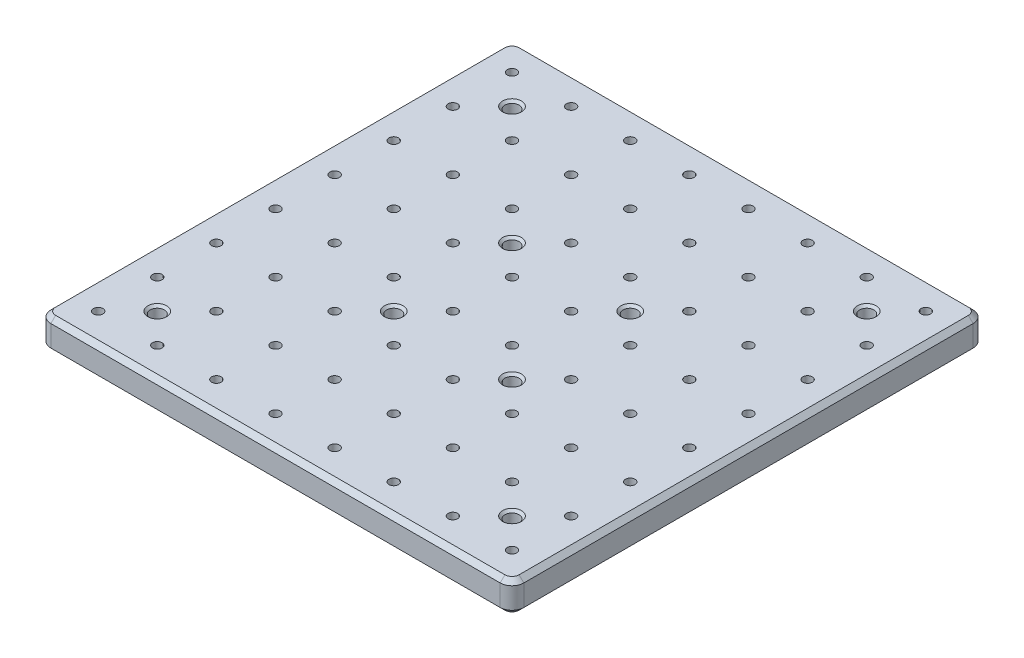
from build123d import *

# Parameters (mm, degrees)
SKETCH_1_R      = 3
SKETCH_1_R_2    = 2
EXTRUDE_1_DEPTH = 13
CHAMFER_1_SIZE  = 2
CHAMFER_2_SIZE  = 1


with BuildPart() as part:
    # 草图1 → 凸台-拉伸1 (new body)
    with BuildSketch(Plane(origin=(0, 0, 0), x_dir=(1, 0, 0), z_dir=(0, 1, 0))):
        with BuildLine():
            Line((95, 100), (-95, 100))
            ThreePointArc((-95, 100), (-98.535533906, 98.535533906), (-100, 95))
            Line((-100, 95), (-100, -95))
            ThreePointArc((-100, -95), (-98.535533906, -98.535533906), (-95, -100))
            Line((-95, -100), (95, -100))
            ThreePointArc((95, -100), (98.535533906, -98.535533906), (100, -95))
            Line((100, -95), (100, 95))
            ThreePointArc((100, 95), (98.535533906, 98.535533906), (95, 100))
        make_face()
        with Locations((-25, 25)):
            Circle(SKETCH_1_R, mode=Mode.SUBTRACT)
        with Locations((25, 25)):
            Circle(SKETCH_1_R, mode=Mode.SUBTRACT)
        with Locations((-25, -25)):
            Circle(SKETCH_1_R, mode=Mode.SUBTRACT)
        with Locations((25, -25)):
            Circle(SKETCH_1_R, mode=Mode.SUBTRACT)
        with Locations((-37.5, 37.5)):
            Circle(SKETCH_1_R_2, mode=Mode.SUBTRACT)
        with Locations((-12.5, 37.5)):
            Circle(SKETCH_1_R_2, mode=Mode.SUBTRACT)
        with Locations((-12.5, 12.5)):
            Circle(SKETCH_1_R_2, mode=Mode.SUBTRACT)
        with Locations((-37.5, 12.5)):
            Circle(SKETCH_1_R_2, mode=Mode.SUBTRACT)
        with Locations((37.5, 37.5)):
            Circle(SKETCH_1_R_2, mode=Mode.SUBTRACT)
        with Locations((37.5, 12.5)):
            Circle(SKETCH_1_R_2, mode=Mode.SUBTRACT)
        with Locations((12.5, 12.5)):
            Circle(SKETCH_1_R_2, mode=Mode.SUBTRACT)
        with Locations((12.5, 37.5)):
            Circle(SKETCH_1_R_2, mode=Mode.SUBTRACT)
        with Locations((87.5, 37.5)):
            Circle(SKETCH_1_R_2, mode=Mode.SUBTRACT)
        with Locations((87.5, 12.5)):
            Circle(SKETCH_1_R_2, mode=Mode.SUBTRACT)
        with Locations((62.5, 12.5)):
            Circle(SKETCH_1_R_2, mode=Mode.SUBTRACT)
        with Locations((62.5, 37.5)):
            Circle(SKETCH_1_R_2, mode=Mode.SUBTRACT)
        with Locations((-87.5, 37.5)):
            Circle(SKETCH_1_R_2, mode=Mode.SUBTRACT)
        with Locations((-62.5, 37.5)):
            Circle(SKETCH_1_R_2, mode=Mode.SUBTRACT)
        with Locations((-62.5, 12.5)):
            Circle(SKETCH_1_R_2, mode=Mode.SUBTRACT)
        with Locations((-87.5, 12.5)):
            Circle(SKETCH_1_R_2, mode=Mode.SUBTRACT)
        with Locations((-37.5, 87.5)):
            Circle(SKETCH_1_R_2, mode=Mode.SUBTRACT)
        with Locations((-12.5, 87.5)):
            Circle(SKETCH_1_R_2, mode=Mode.SUBTRACT)
        with Locations((-12.5, 62.5)):
            Circle(SKETCH_1_R_2, mode=Mode.SUBTRACT)
        with Locations((-37.5, 62.5)):
            Circle(SKETCH_1_R_2, mode=Mode.SUBTRACT)
        with Locations((37.5, 87.5)):
            Circle(SKETCH_1_R_2, mode=Mode.SUBTRACT)
        with Locations((37.5, 62.5)):
            Circle(SKETCH_1_R_2, mode=Mode.SUBTRACT)
        with Locations((12.5, 62.5)):
            Circle(SKETCH_1_R_2, mode=Mode.SUBTRACT)
        with Locations((12.5, 87.5)):
            Circle(SKETCH_1_R_2, mode=Mode.SUBTRACT)
        with Locations((87.5, 87.5)):
            Circle(SKETCH_1_R_2, mode=Mode.SUBTRACT)
        with Locations((87.5, 62.5)):
            Circle(SKETCH_1_R_2, mode=Mode.SUBTRACT)
        with Locations((62.5, 62.5)):
            Circle(SKETCH_1_R_2, mode=Mode.SUBTRACT)
        with Locations((62.5, 87.5)):
            Circle(SKETCH_1_R_2, mode=Mode.SUBTRACT)
        with Locations((-87.5, 87.5)):
            Circle(SKETCH_1_R_2, mode=Mode.SUBTRACT)
        with Locations((-62.5, 87.5)):
            Circle(SKETCH_1_R_2, mode=Mode.SUBTRACT)
        with Locations((-62.5, 62.5)):
            Circle(SKETCH_1_R_2, mode=Mode.SUBTRACT)
        with Locations((-87.5, 62.5)):
            Circle(SKETCH_1_R_2, mode=Mode.SUBTRACT)
        with Locations((-37.5, -12.5)):
            Circle(SKETCH_1_R_2, mode=Mode.SUBTRACT)
        with Locations((-12.5, -12.5)):
            Circle(SKETCH_1_R_2, mode=Mode.SUBTRACT)
        with Locations((-12.5, -37.5)):
            Circle(SKETCH_1_R_2, mode=Mode.SUBTRACT)
        with Locations((-37.5, -37.5)):
            Circle(SKETCH_1_R_2, mode=Mode.SUBTRACT)
        with Locations((37.5, -12.5)):
            Circle(SKETCH_1_R_2, mode=Mode.SUBTRACT)
        with Locations((37.5, -37.5)):
            Circle(SKETCH_1_R_2, mode=Mode.SUBTRACT)
        with Locations((12.5, -37.5)):
            Circle(SKETCH_1_R_2, mode=Mode.SUBTRACT)
        with Locations((12.5, -12.5)):
            Circle(SKETCH_1_R_2, mode=Mode.SUBTRACT)
        with Locations((87.5, -12.5)):
            Circle(SKETCH_1_R_2, mode=Mode.SUBTRACT)
        with Locations((87.5, -37.5)):
            Circle(SKETCH_1_R_2, mode=Mode.SUBTRACT)
        with Locations((62.5, -37.5)):
            Circle(SKETCH_1_R_2, mode=Mode.SUBTRACT)
        with Locations((62.5, -12.5)):
            Circle(SKETCH_1_R_2, mode=Mode.SUBTRACT)
        with Locations((-87.5, -12.5)):
            Circle(SKETCH_1_R_2, mode=Mode.SUBTRACT)
        with Locations((-62.5, -12.5)):
            Circle(SKETCH_1_R_2, mode=Mode.SUBTRACT)
        with Locations((-62.5, -37.5)):
            Circle(SKETCH_1_R_2, mode=Mode.SUBTRACT)
        with Locations((-87.5, -37.5)):
            Circle(SKETCH_1_R_2, mode=Mode.SUBTRACT)
        with Locations((-37.5, -62.5)):
            Circle(SKETCH_1_R_2, mode=Mode.SUBTRACT)
        with Locations((-12.5, -62.5)):
            Circle(SKETCH_1_R_2, mode=Mode.SUBTRACT)
        with Locations((-12.5, -87.5)):
            Circle(SKETCH_1_R_2, mode=Mode.SUBTRACT)
        with Locations((-37.5, -87.5)):
            Circle(SKETCH_1_R_2, mode=Mode.SUBTRACT)
        with Locations((37.5, -62.5)):
            Circle(SKETCH_1_R_2, mode=Mode.SUBTRACT)
        with Locations((37.5, -87.5)):
            Circle(SKETCH_1_R_2, mode=Mode.SUBTRACT)
        with Locations((12.5, -87.5)):
            Circle(SKETCH_1_R_2, mode=Mode.SUBTRACT)
        with Locations((12.5, -62.5)):
            Circle(SKETCH_1_R_2, mode=Mode.SUBTRACT)
        with Locations((87.5, -62.5)):
            Circle(SKETCH_1_R_2, mode=Mode.SUBTRACT)
        with Locations((87.5, -87.5)):
            Circle(SKETCH_1_R_2, mode=Mode.SUBTRACT)
        with Locations((62.5, -87.5)):
            Circle(SKETCH_1_R_2, mode=Mode.SUBTRACT)
        with Locations((62.5, -62.5)):
            Circle(SKETCH_1_R_2, mode=Mode.SUBTRACT)
        with Locations((-87.5, -62.5)):
            Circle(SKETCH_1_R_2, mode=Mode.SUBTRACT)
        with Locations((-62.5, -62.5)):
            Circle(SKETCH_1_R_2, mode=Mode.SUBTRACT)
        with Locations((-62.5, -87.5)):
            Circle(SKETCH_1_R_2, mode=Mode.SUBTRACT)
        with Locations((-87.5, -87.5)):
            Circle(SKETCH_1_R_2, mode=Mode.SUBTRACT)
        with Locations((-75, 75)):
            Circle(SKETCH_1_R, mode=Mode.SUBTRACT)
        with Locations((-75, -75)):
            Circle(SKETCH_1_R, mode=Mode.SUBTRACT)
        with Locations((75, 75)):
            Circle(SKETCH_1_R, mode=Mode.SUBTRACT)
        with Locations((75, -75)):
            Circle(SKETCH_1_R, mode=Mode.SUBTRACT)
    extrude(amount=EXTRUDE_1_DEPTH)

    # 倒角1
    chamfer_1_edges = [part.edges().sort_by_distance(p)[0] for p in [
        (0, 0, -100),
        (98.535533906, 0, -98.535533906),
        (100, 0, 0),
        (98.535533906, 0, 98.535533906),
        (98.535533906, 13, -98.535533906),
        (0, 13, -100),
        (-98.535533906, 13, -98.535533906),
        (-100, 13, 0),
        (-98.535533906, 13, 98.535533906),
        (0, 13, 100),
        (98.535533906, 13, 98.535533906),
        (0, 0, 100),
        (100, 13, 0),
        (-98.535533906, 0, 98.535533906),
        (-100, 0, 0),
        (-98.535533906, 0, -98.535533906),
    ]]
    chamfer(chamfer_1_edges, length=CHAMFER_1_SIZE)

    # 倒角2
    chamfer_2_edges = [part.edges().sort_by_distance(p)[0] for p in [
        (-28, 0, -25),
        (-28, 13, -25),
        (22, 0, -25),
        (22, 13, -25),
        (-78, 0, -75),
        (-78, 13, -75),
        (-78, 0, 75),
        (-78, 13, 75),
        (72, 0, -75),
        (72, 13, -75),
        (72, 0, 75),
        (72, 13, 75),
        (-28, 0, 25),
        (-28, 13, 25),
        (22, 0, 25),
        (22, 13, 25),
    ]]
    chamfer(chamfer_2_edges, length=CHAMFER_2_SIZE)


solid = part.part
